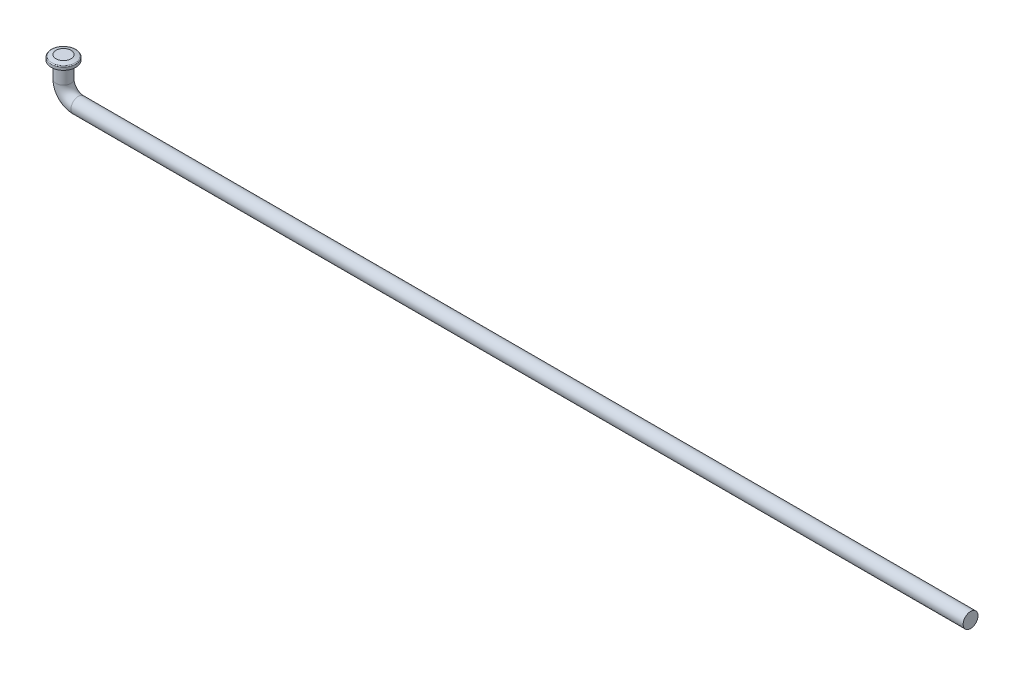
from build123d import *

# Parameters (mm, degrees)
SKETCH_12_ON_SEGMENT_1_R = 1.5
ROUND_D3MM_1_DEPTH       = 3
SKETCH_12_ON_SEGMENT_2_R = 1.5
ROUND_D3MM_1_2_ANGLE     = 90
SKETCH_12_R              = 1.5
ROUND_D3MM_1_3_DEPTH     = 180
SKETCH_13_R              = 2.5
EXTRUDE_1_DEPTH          = 1.3
CHAMFER_1_SIZE           = 0.3
CHAMFER_1_SIZE2          = 1
CHAMFER_2_SIZE           = 0.3
CHAMFER_2_SIZE2          = 0.781526719
FILLET_5_R               = 0.2


with BuildPart() as part:
    # Эскиз12 on segment 1 (carried to segment 1) → Round D3MM(1) (new body)
    with BuildSketch(Plane(origin=(-93, 3, 0), x_dir=(-1, 0, 0), z_dir=(0, 1, 0))):
        Circle(SKETCH_12_ON_SEGMENT_1_R)
    extrude(amount=ROUND_D3MM_1_DEPTH)


with BuildPart() as body_2:
    # Эскиз12 on segment 2 (carried to the start of arc 2) → Round D3MM_1 2 (revolve)
    with BuildSketch(Plane(origin=(-90, 0, 0), x_dir=(0, -1, 0), z_dir=(-1, 0, 0))):
        Circle(SKETCH_12_ON_SEGMENT_2_R)
    revolve(axis=Axis((-90, 3, 0), (0, 0, -1)), revolution_arc=ROUND_D3MM_1_2_ANGLE)


with BuildPart() as body_3:
    # Эскиз12 → Round D3MM_1 3 (new body)
    with BuildSketch(Plane.YZ.offset(-90)):
        Circle(SKETCH_12_R)
    extrude(amount=ROUND_D3MM_1_3_DEPTH)


with BuildPart() as part_1:
    add(part.part)

    # Round D3MM(1) as one body: union body 2, body 3
    add(body_2.part)
    add(body_3.part)


with BuildPart() as body_2_2:
    # Эскиз13 → Бобышка-Вытянуть1 (new body)
    with BuildSketch(Plane(origin=(0, 6, 0), x_dir=(1, 0, 0), z_dir=(0, 1, 0))):
        with Locations(Location((-93, 0, 0), (0, 0, 180))):
            Circle(SKETCH_13_R)
    extrude(amount=EXTRUDE_1_DEPTH)

    # Фаска1
    chamfer_1_edges = [body_2_2.edges().sort_by_distance(p)[0] for p in [
        (-90.5, 7.3, 0),
    ]]
    chamfer_1_side = [body_2_2.faces().sort_by_distance(p)[0] for p in [
        (-90.5, 6.65, 0),
    ]]
    chamfer(chamfer_1_edges, length=CHAMFER_1_SIZE, length2=CHAMFER_1_SIZE2, reference=chamfer_1_side[0])

    # Фаска2
    chamfer_2_edges = [body_2_2.edges().sort_by_distance(p)[0] for p in [
        (-90.5, 6, 0),
    ]]
    chamfer_2_side = [body_2_2.faces().sort_by_distance(p)[0] for p in [
        (-90.5, 6.5, 0),
    ]]
    chamfer(chamfer_2_edges, length=CHAMFER_2_SIZE, length2=CHAMFER_2_SIZE2, reference=chamfer_2_side[0])

    # Скругление5
    fillet_5_edges = [body_2_2.edges().sort_by_distance(p)[0] for p in [
        (-90.5, 7, 0),
    ]]
    fillet(fillet_5_edges, radius=FILLET_5_R)


solid = Compound([part_1.part, body_2_2.part])
